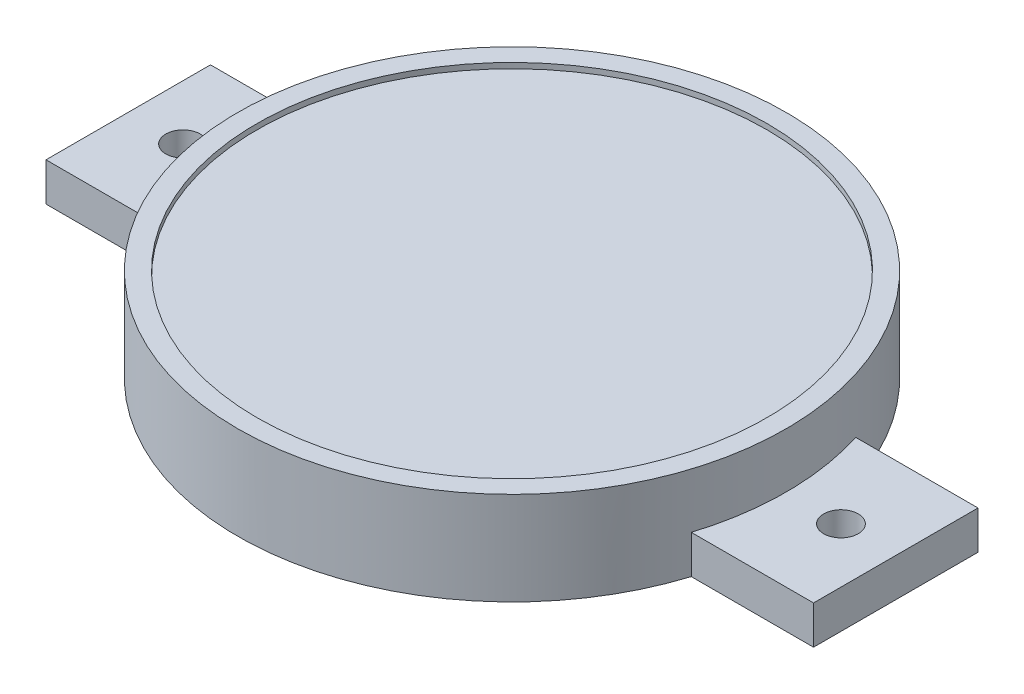
from build123d import *

# Parameters (mm, degrees)
SKETCH1_R           = 50
BOSS_EXTRUDE1_DEPTH = 16
SKETCH2_R           = 50
SKETCH2_R_2         = 46.5
BOSS_EXTRUDE2_DEPTH = 1
SKETCH3_R           = 47
CUT_EXTRUDE1_DEPTH  = 10
SKETCH4_R           = 3.15
BOSS_EXTRUDE3_DEPTH = 7


with BuildPart() as part:
    # Sketch1 → Boss-Extrude1 (new body)
    with BuildSketch(Plane(origin=(0, 0, 0), x_dir=(1, 0, 0), z_dir=(0, 1, 0))):
        Circle(SKETCH1_R)
    extrude(amount=BOSS_EXTRUDE1_DEPTH)

    # Sketch2 → Boss-Extrude2 (add)
    with BuildSketch(Plane(origin=(0, 16, 0), x_dir=(1, 0, 0), z_dir=(0, 1, 0))):
        Circle(SKETCH2_R)
        Circle(SKETCH2_R_2, mode=Mode.SUBTRACT)
    extrude(amount=BOSS_EXTRUDE2_DEPTH)

    # Sketch3 → Cut-Extrude1 (cut)
    with BuildSketch(Plane.XZ):
        Circle(SKETCH3_R)
    extrude(amount=-CUT_EXTRUDE1_DEPTH, mode=Mode.SUBTRACT)

    # Sketch4 → Boss-Extrude3 (add)
    with BuildSketch(Plane(origin=(0, 0, 0), x_dir=(1, 0, 0), z_dir=(0, 1, 0))):
        with BuildLine():
            Line((-47.696960071, 15), (-70, 15))
            Line((-70, 15), (-70, -15))
            Line((-70, -15), (-47.696960071, -15))
            ThreePointArc((-47.696960071, -15), (-50, 0), (-47.696960071, 15))
        make_face()
        with Locations((-60, 0)):
            Circle(SKETCH4_R, mode=Mode.SUBTRACT)
        with BuildLine():
            Line((47.696960071, -15), (70, -15))
            Line((70, -15), (70, 15))
            Line((70, 15), (47.696960071, 15))
            ThreePointArc((47.696960071, 15), (50, 0), (47.696960071, -15))
        make_face()
        with Locations((60, 0)):
            Circle(SKETCH4_R, mode=Mode.SUBTRACT)
    extrude(amount=BOSS_EXTRUDE3_DEPTH)


solid = part.part
